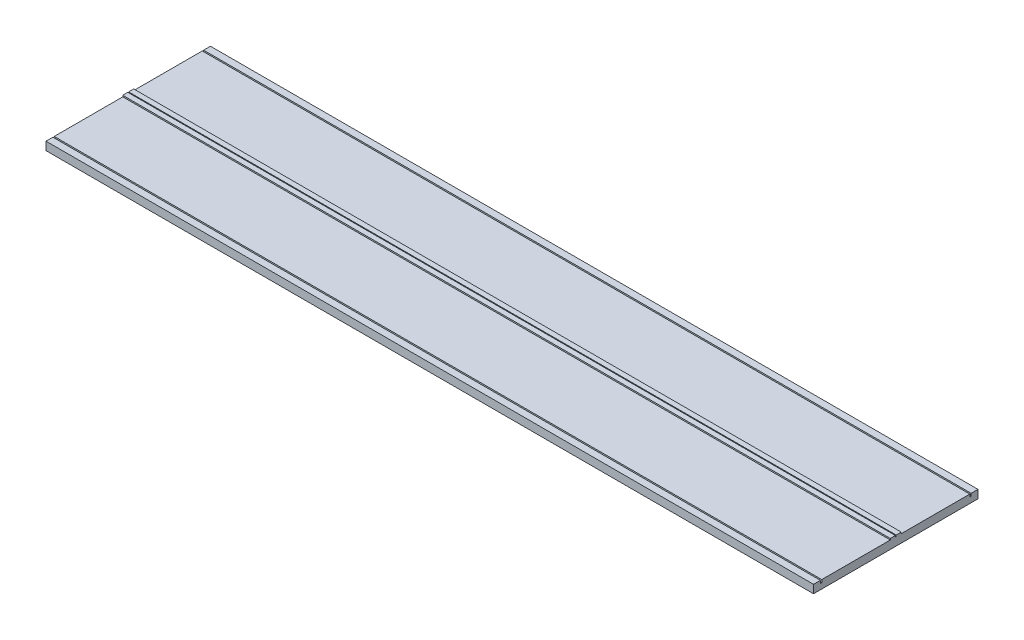
from build123d import *

# Parameters (mm, degrees)
SKETCH1_W           = 280
SKETCH1_H           = 60
BOSS_EXTRUDE1_DEPTH = 3
SKETCH1_9_W         = 280
SKETCH1_9_H         = 0.5
CUT_EXTRUDE1_DEPTH  = 1
BOSS_EXTRUDE2_DEPTH = 280
SKETCH3_W           = 0.3
SKETCH3_H           = 0.5
CUT_EXTRUDE5_DEPTH  = 280


with BuildPart() as part:
    # Sketch1 → Boss-Extrude1 (new body)
    with BuildSketch(Plane(origin=(0, 0, 0), x_dir=(1, 0, 0), z_dir=(0, 1, 0))):
        Rectangle(SKETCH1_W, SKETCH1_H)
    extrude(amount=-BOSS_EXTRUDE1_DEPTH)

    # Sketch1_9 → Cut-Extrude1 (cut)
    with BuildSketch(Plane(origin=(0, 0, 0), x_dir=(1, 0, 0), z_dir=(0, 1, 0))):
        with Locations((0, 27.25)):
            Rectangle(SKETCH1_9_W, SKETCH1_9_H)
    cut_extrude1 = extrude(amount=-CUT_EXTRUDE1_DEPTH, mode=Mode.SUBTRACT)

    # Mirror1: Cut-Extrude1 across plane
    add(cut_extrude1.mirror(Plane.XY), mode=Mode.SUBTRACT)

    # Sketch2 → Boss-Extrude2 (add)
    with BuildSketch(Plane(origin=(140, 0, 0), x_dir=(0, 0, -1), z_dir=(1, 0, 0))):
        Polygon((0, 0.5), (2, 0.5), (2, 0), (-2, 0), (-2, 0.5), align=None)
    extrude(amount=-BOSS_EXTRUDE2_DEPTH)

    # Sketch3 → Cut-Extrude5 (cut)
    with BuildSketch(Plane(origin=(140, 0, 0), x_dir=(0, 0, -1), z_dir=(1, 0, 0))):
        with Locations((0, 0.25)):
            Rectangle(SKETCH3_W, SKETCH3_H)
    extrude(amount=-CUT_EXTRUDE5_DEPTH, mode=Mode.SUBTRACT)


solid = part.part
